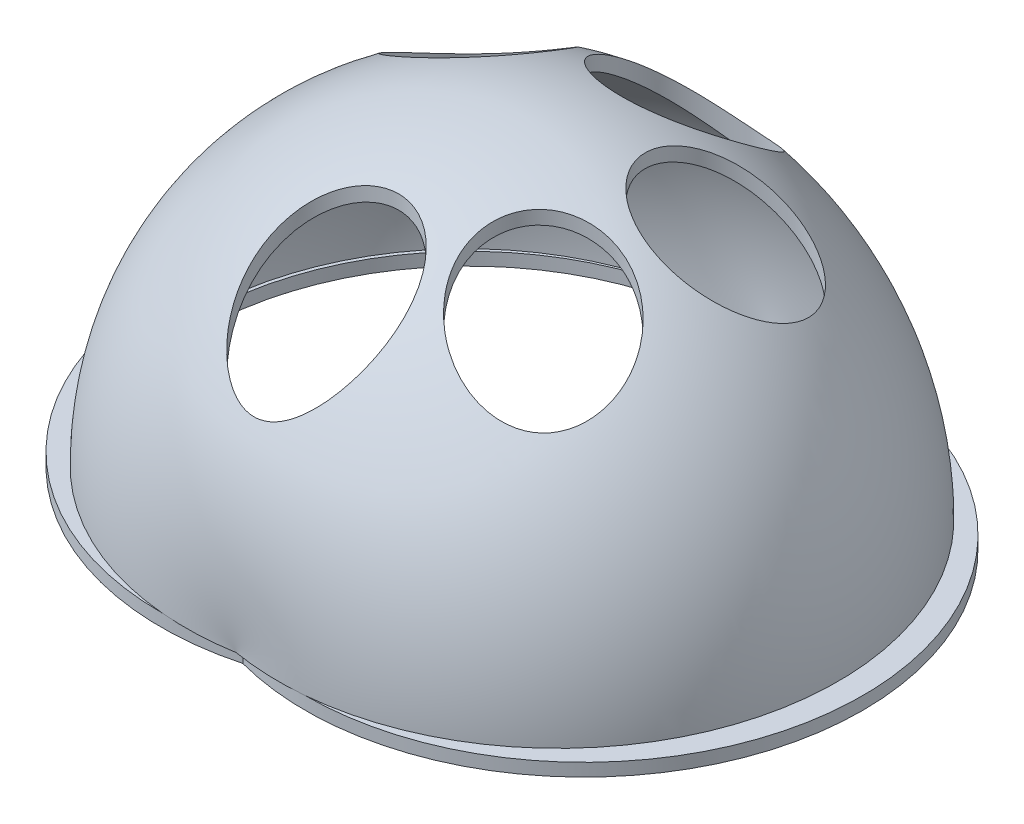
from build123d import *

# Parameters (mm, degrees)
BOSS_EXTRUDE1_DEPTH = 2
REVOLVE1_ANGLE      = 180
SKETCH3_R           = 11
CUT_EXTRUDE1_DEPTH  = 62


with BuildPart() as part:
    # Sketch2 → Boss-Extrude1 (new body)
    with BuildSketch(Plane(origin=(0, 0, 0), x_dir=(1, 0, 0), z_dir=(0, 1, 0))):
        with BuildLine():
            ThreePointArc((0, 41.951120217), (-54.646513842, 0), (0, -41.951120217))
            ThreePointArc((0, -41.951120217), (54.646513842, 0), (0, 41.951120217))
        make_face()
        with BuildLine():
            ThreePointArc((0, 41.075702611), (-48.321637686, -0.373675007), (0, -41.823052625))
            ThreePointArc((0, -41.823052625), (48.321637686, -0.373675007), (0, 41.075702611))
        make_face(mode=Mode.SUBTRACT)
    extrude(amount=BOSS_EXTRUDE1_DEPTH)

    # Sketch4 → Revolve1 (revolve)
    with BuildSketch(Plane(origin=(0, 2, 0), x_dir=(1, 0, 0), z_dir=(0, 1, 0))):
        with BuildLine():
            Line((0, 43), (0, 41))
            ThreePointArc((0, 41), (48.776568385, 0), (0, -41))
            Line((0, -41), (0, -43))
            ThreePointArc((0, -43), (50.805740161, 0), (0, 43))
        make_face()
    revolve(axis=Axis((0, 2, -43), (0, 0, 1)), revolution_arc=REVOLVE1_ANGLE)

    # Sketch3 → Cut-Extrude1 (cut)
    with BuildSketch(Plane(origin=(0, 0, 0), x_dir=(1, 0, 0), z_dir=(0, 1, 0))):
        with Locations((-20.992657981, 15.776690814)):
            Circle(SKETCH3_R)
        with Locations((2.31820763, 24.534364082)):
            Circle(SKETCH3_R)
        with Locations((23.697233549, 9.594803801)):
            Circle(SKETCH3_R)
        with Locations((20.404951697, -15.520747594)):
            Circle(SKETCH3_R)
        with Locations((-1.803050379, -27.110150337)):
            Circle(SKETCH3_R)
    extrude(amount=CUT_EXTRUDE1_DEPTH, mode=Mode.SUBTRACT)


solid = part.part
